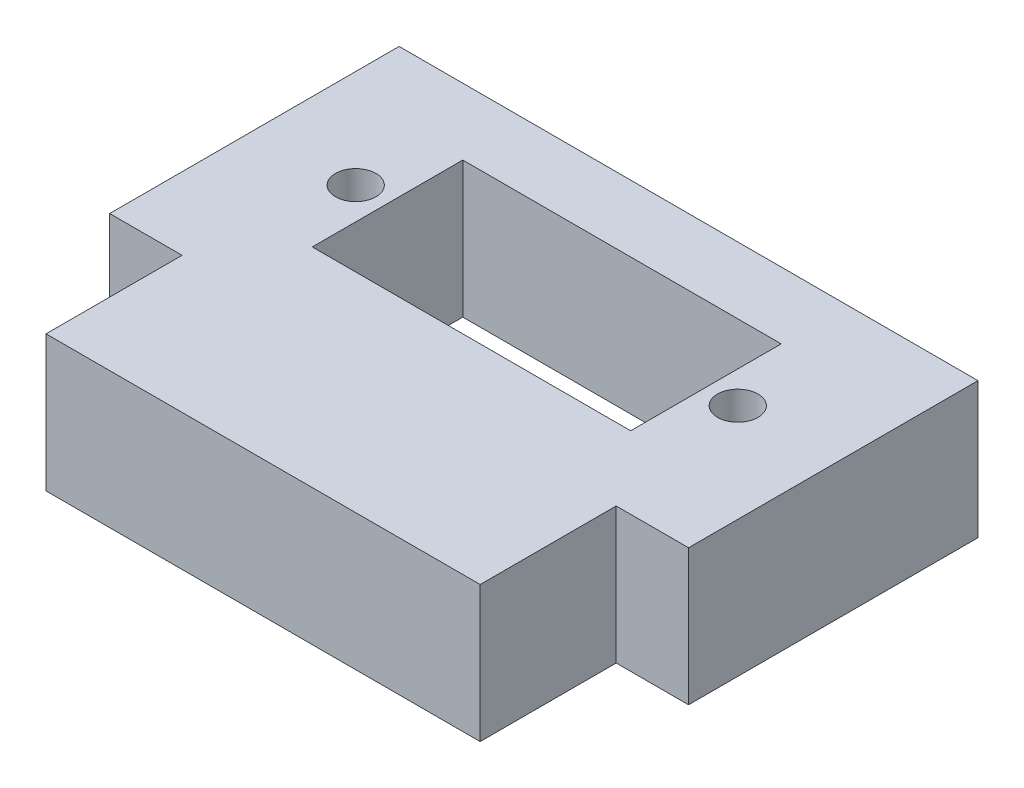
from build123d import *

# Parameters (mm, degrees)
TILT_MOUNT_DEPTH              = 11.938
SERVO_HOLE_SKETCH_W           = 27.94
SERVO_HOLE_SKETCH_H           = 13.208
SERVO_HOLE_DEPTH              = 12.938
MOUNTING_HOLES_GUIDE_SKETCH_R = 1.778
MOUNTING_HOLES_DEPTH          = 12.938


with BuildPart() as part:
    # Tilt Mount Sketch → Tilt Mount (new body)
    with BuildSketch(Plane(origin=(0, 0, 0), x_dir=(1, 0, 0), z_dir=(0, 1, 0))):
        Polygon((44.45, 0), (50.8, 0), (50.8, 25.4), (0, 25.4), (0, 0), (6.35, 0), (6.35, -11.938), (44.45, -11.938), align=None)
    extrude(amount=TILT_MOUNT_DEPTH)

    # Servo Hole Sketch → Servo Hole (cut, through all)
    with BuildSketch(Plane(origin=(0, 11.938, 0), x_dir=(1, 0, 0), z_dir=(0, 1, 0))):
        with Locations((25.4, 12.954)):
            Rectangle(SERVO_HOLE_SKETCH_W, SERVO_HOLE_SKETCH_H)
    extrude(amount=-SERVO_HOLE_DEPTH, mode=Mode.SUBTRACT)

    # Mounting Holes Guide Sketch → Mounting Holes (cut, through all)
    with BuildSketch(Plane(origin=(0, 11.938, 0), x_dir=(1, 0, 0), z_dir=(0, 1, 0))):
        with Locations((8.636, 12.954)):
            Circle(MOUNTING_HOLES_GUIDE_SKETCH_R)
        with Locations((42.164, 12.954)):
            Circle(MOUNTING_HOLES_GUIDE_SKETCH_R)
    extrude(amount=-MOUNTING_HOLES_DEPTH, mode=Mode.SUBTRACT)


solid = part.part
